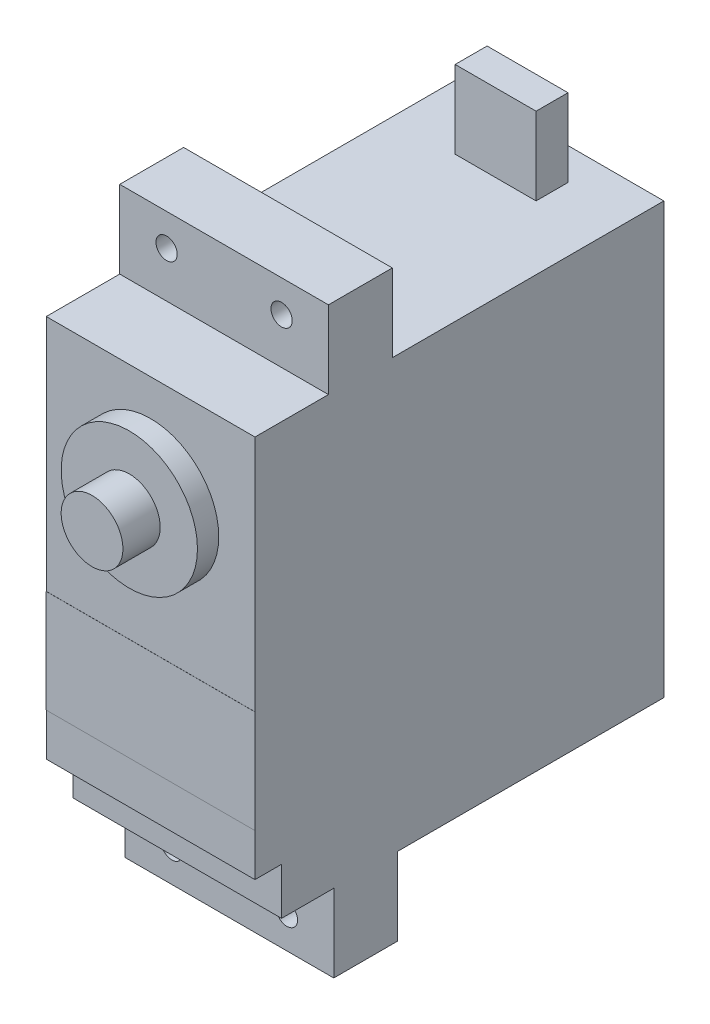
from build123d import *

# Parameters (mm, degrees)
SKETCH_2_W          = 19.6
SKETCH_2_H          = 40.4
EXTRUDE_2_DEPTH     = 35.9
SKETCH_8_W          = 19.6
SKETCH_8_H          = 36
EXTRUDE_4_DEPTH     = 2.5
EXTRUDE_5_DEPTH     = 7.3
EXTRUDE_6_DEPTH     = 7.3
EXTRUDE_7_DEPTH     = 7.3
SKETCH_13_R         = 6.4
EXTRUDE_8_DEPTH     = 2
SKETCH_15_R         = 2.9
EXTRUDE_9_DEPTH     = 3.5
SKETCH_16_W         = 19.6
SKETCH_16_H         = 9.65
EXTRUDE_10_DEPTH    = 0.01
SKETCH_17_R         = 1
CUT_EXTRUDE_1_DEPTH = 10
CUT_EXTRUDE_2_DEPTH = 10
SKETCH_19_R         = 1
CUT_EXTRUDE_3_DEPTH = 10


with BuildPart() as part:
    # ｽｹｯﾁ2 → ﾎﾞｽ - 押し出し2 (new body)
    with BuildSketch(Plane.XY):
        with Locations((25.664618486, 0.22320442)):
            Rectangle(SKETCH_2_W, SKETCH_2_H)
    extrude(amount=EXTRUDE_2_DEPTH)

    # ｽｹｯﾁ8 → ﾎﾞｽ - 押し出し4 (add)
    with BuildSketch(Plane.XY.offset(35.9)):
        with Locations((25.664618486, 2.42320442)):
            Rectangle(SKETCH_8_W, SKETCH_8_H)
    extrude(amount=EXTRUDE_4_DEPTH)

    # ｽｹｯﾁ9 → ﾎﾞｽ - 押し出し5 (add)
    with BuildSketch(Plane(origin=(0, 20.42320442, 0), x_dir=(1, 0, 0), z_dir=(0, 1, 0))):
        Polygon((35.464618486, -31.499834605), (35.464618486, -25.499834605), (25.664618486, -25.499834605), (15.864618486, -25.499834605), (15.864618486, -31.499834605), align=None)
    extrude(amount=EXTRUDE_5_DEPTH)

    # ｽｹｯﾁ10 → ﾎﾞｽ - 押し出し6 (add)
    with BuildSketch(Plane.XZ.offset(19.97679558)):
        Polygon((15.864618486, 31), (15.864618486, 25), (25.664618486, 25), (35.464618486, 25), (35.464618486, 31), align=None)
    extrude(amount=EXTRUDE_6_DEPTH)

    # ｽｹｯﾁ11 → ﾎﾞｽ - 押し出し7 (add)
    with BuildSketch(Plane(origin=(0, 20.42320442, 0), x_dir=(1, 0, 0), z_dir=(0, 1, 0))):
        Polygon((29.464618486, -3), (25.664618486, -3), (21.864618486, -3), (21.864618486, -6), (29.464618486, -6), align=None)
    extrude(amount=EXTRUDE_7_DEPTH)

    # ｽｹｯﾁ13 → ﾎﾞｽ - 押し出し8 (add)
    with BuildSketch(Plane.XY.offset(38.4)):
        with Locations((25.664618486, 10.62320442)):
            Circle(SKETCH_13_R)
    extrude(amount=EXTRUDE_8_DEPTH)

    # ｽｹｯﾁ15 → ﾎﾞｽ - 押し出し9 (add)
    with BuildSketch(Plane.XY.offset(40.4)):
        with Locations((25.664618486, 10.62320442)):
            Circle(SKETCH_15_R)
    extrude(amount=EXTRUDE_9_DEPTH)

    # ｽｹｯﾁ16 → ﾎﾞｽ - 押し出し10 (add)
    with BuildSketch(Plane.XY.offset(38.4)):
        with Locations((25.664618486, -6.75179558)):
            Rectangle(SKETCH_16_W, SKETCH_16_H)
    extrude(amount=EXTRUDE_10_DEPTH)

    # ｽｹｯﾁ17 → ｶｯﾄ - 押し出し1 (cut)
    with BuildSketch(Plane.XY.offset(31.499834605)):
        with Locations((31.064618486, 24.72320442)):
            Circle(SKETCH_17_R)
    extrude(amount=-CUT_EXTRUDE_1_DEPTH, mode=Mode.SUBTRACT)

    # ｽｹｯﾁ18 → ｶｯﾄ - 押し出し2 (cut)
    with BuildSketch(Plane.XY.offset(31.499834605)):
        with BuildLine():
            ThreePointArc((21.264618486, 24.72320442), (20.971725267, 25.430311201), (20.264618486, 25.72320442))
            Line((20.264618486, 25.72320442), (20.264618486, 24.72320442))
            Line((20.264618486, 24.72320442), (19.264618486, 24.72320442))
            ThreePointArc((19.264618486, 24.72320442), (20.264618486, 23.72320442), (21.264618486, 24.72320442))
        make_face()
        with BuildLine():
            Line((20.264618486, 24.72320442), (20.264618486, 25.72320442))
            ThreePointArc((20.264618486, 25.72320442), (19.557511705, 25.430311201), (19.264618486, 24.72320442))
            Line((19.264618486, 24.72320442), (20.264618486, 24.72320442))
        make_face()
    extrude(amount=-CUT_EXTRUDE_2_DEPTH, mode=Mode.SUBTRACT)

    # ｽｹｯﾁ19 → ｶｯﾄ - 押し出し3 (cut)
    with BuildSketch(Plane.XY.offset(31)):
        with Locations((20.264618486, -24.27679558)):
            Circle(SKETCH_19_R)
        with Locations((31.064618486, -24.27679558)):
            Circle(SKETCH_19_R)
    extrude(amount=-CUT_EXTRUDE_3_DEPTH, mode=Mode.SUBTRACT)


solid = part.part
